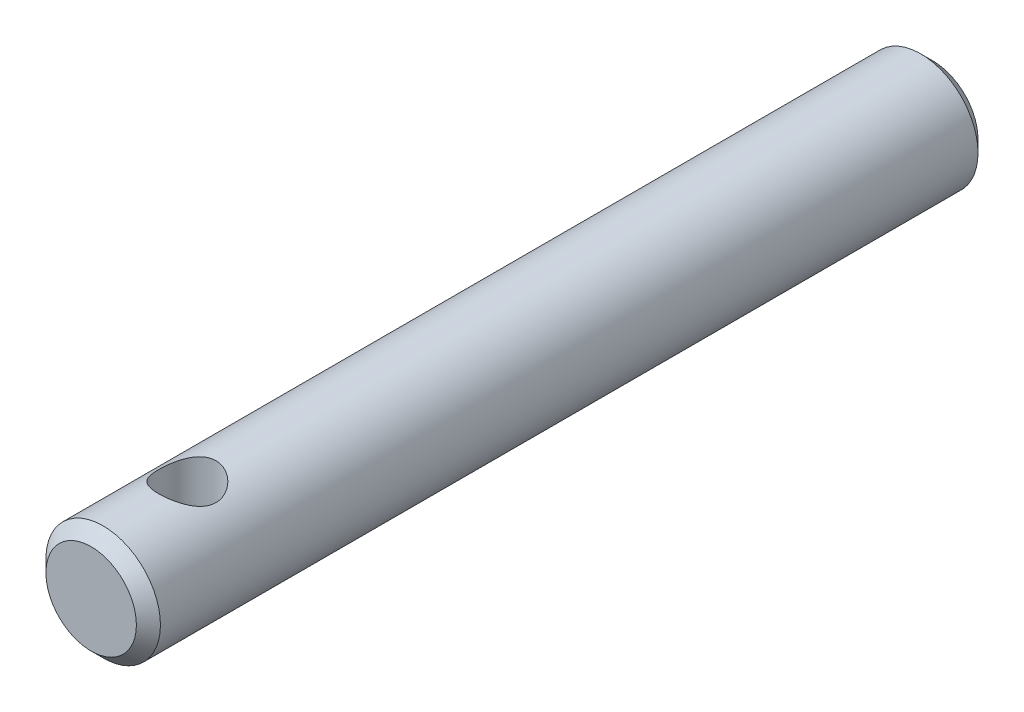
from build123d import *

# Parameters (mm, degrees)
SKETCH1_R               = 2.38125
BOSS_EXTRUDE1_DEPTH     = 17.5
SKETCH2_R               = 1.190625
CUT_EXTRUDE2_DEPTH      = 3.38125
CUT_EXTRUDE2_DEPTH_BACK = 3.38125
CHAMFER1_SIZE           = 0.5


with BuildPart() as part:
    # Sketch1 → Boss-Extrude1 (new body, symmetric)
    with BuildSketch(Plane.XY):
        Circle(SKETCH1_R)
    extrude(amount=BOSS_EXTRUDE1_DEPTH, both=True)

    # Sketch2 → Cut-Extrude2 (cut, two sides)
    with BuildSketch(Plane(origin=(0, 0, 0), x_dir=(1, 0, 0), z_dir=(0, 1, 0))) as cut_extrude2_sk:
        with Locations((0, -13.5)):
            Circle(SKETCH2_R)
    extrude(amount=CUT_EXTRUDE2_DEPTH, mode=Mode.SUBTRACT)
    extrude(cut_extrude2_sk.sketch, amount=-CUT_EXTRUDE2_DEPTH_BACK, mode=Mode.SUBTRACT)

    # Chamfer1
    chamfer1_edges = [part.edges().sort_by_distance(p)[0] for p in [
        (-2.38125, 0, -17.5),
        (-2.38125, 0, 17.5),
    ]]
    chamfer(chamfer1_edges, length=CHAMFER1_SIZE)


solid = part.part
